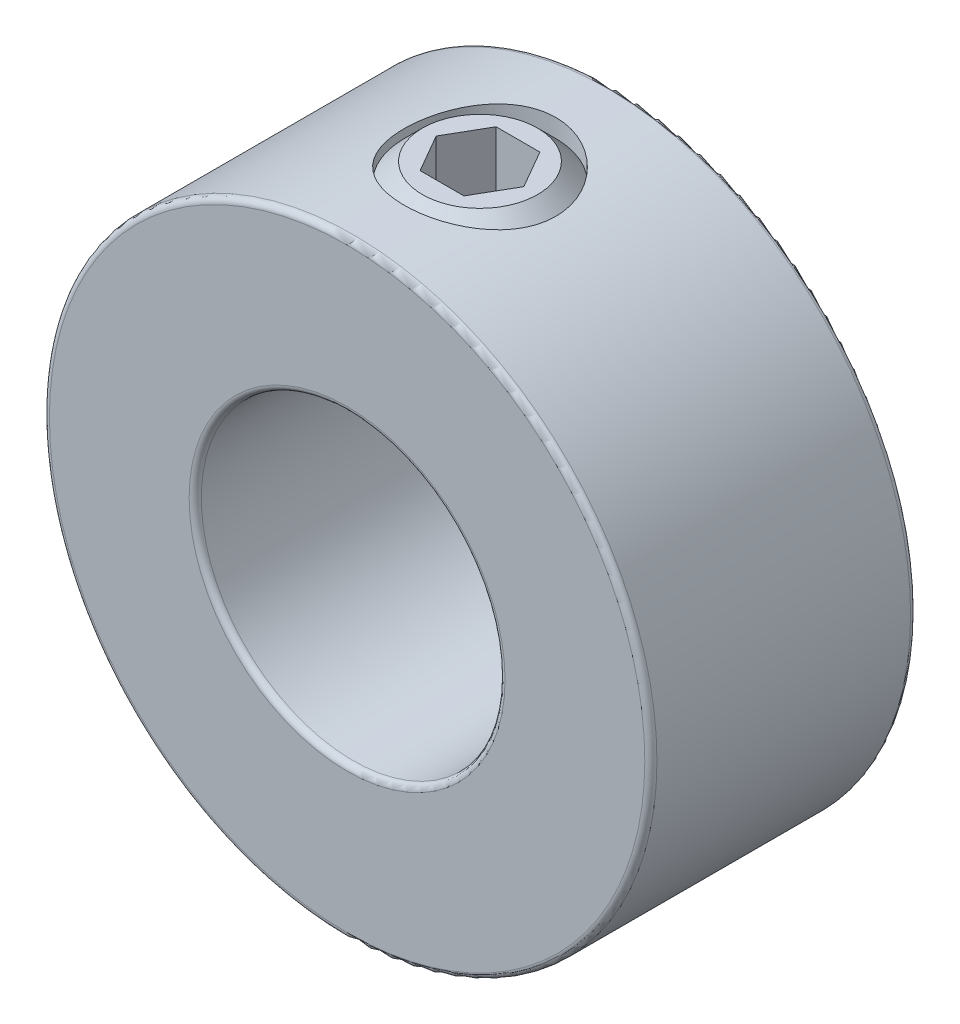
from build123d import *

# Parameters (mm, degrees)
SKETCH1_R          = 12.7
SKETCH1_R_2        = 6.35
EXTRUDE1_DEPTH     = 5.55625
SKETCH2_R          = 3.175
CUT_EXTRUDE1_DEPTH = 13.7
FILLET1_R          = 0.254
CUT_EXTRUDE2_DEPTH = 3.175


with BuildPart() as part:
    # Sketch1 → Extrude1 (new body, symmetric)
    with BuildSketch(Plane.XY):
        Circle(SKETCH1_R)
        Circle(SKETCH1_R_2, mode=Mode.SUBTRACT)
    extrude(amount=EXTRUDE1_DEPTH, both=True)

    # Sketch2 → Cut-Extrude1 (cut, through all)
    with BuildSketch(Plane(origin=(41.275, 0, 0), x_dir=(0, 0, -1), z_dir=(0, -1, 0))):
        with Locations((0, -41.275)):
            Circle(SKETCH2_R)
    extrude(amount=-CUT_EXTRUDE1_DEPTH, mode=Mode.SUBTRACT)

    # Fillet1
    fillet1_edges = [part.edges().sort_by_distance(p)[0] for p in [
        (-12.7, 0, -5.55625),
        (-12.7, 0, 5.55625),
        (-6.35, 0, -5.55625),
        (-6.35, 0, 5.55625),
    ]]
    fillet(fillet1_edges, radius=FILLET1_R)


with BuildPart() as body_2:
    # Sketch3 → Revolve1 (revolve)
    with BuildSketch(Plane.XY):
        Polygon((-2.408192631, 6.35), (-0.920168843, 6.35), (0, 7.270168843), (0, 12.7), (-2.408192631, 12.7), (-3.175, 11.933192631), (-3.175, 7.116807369), align=None)
    revolve(axis=Axis((0, 6.35, 0), (0, -1, 0)))

    # Sketch4 → Cut-Extrude2 (cut)
    with BuildSketch(Plane(origin=(3.3734375, 12.7, 0), x_dir=(0, 0, -1), z_dir=(0, -1, 0))):
        Polygon((0, -1.540350395), (-1.5875, -2.456893948), (-1.5875, -4.289981052), (0, -5.206524605), (1.5875, -4.289981052), (1.5875, -2.456893948), align=None)
    extrude(amount=CUT_EXTRUDE2_DEPTH, mode=Mode.SUBTRACT)


solid = Compound([part.part, body_2.part])
